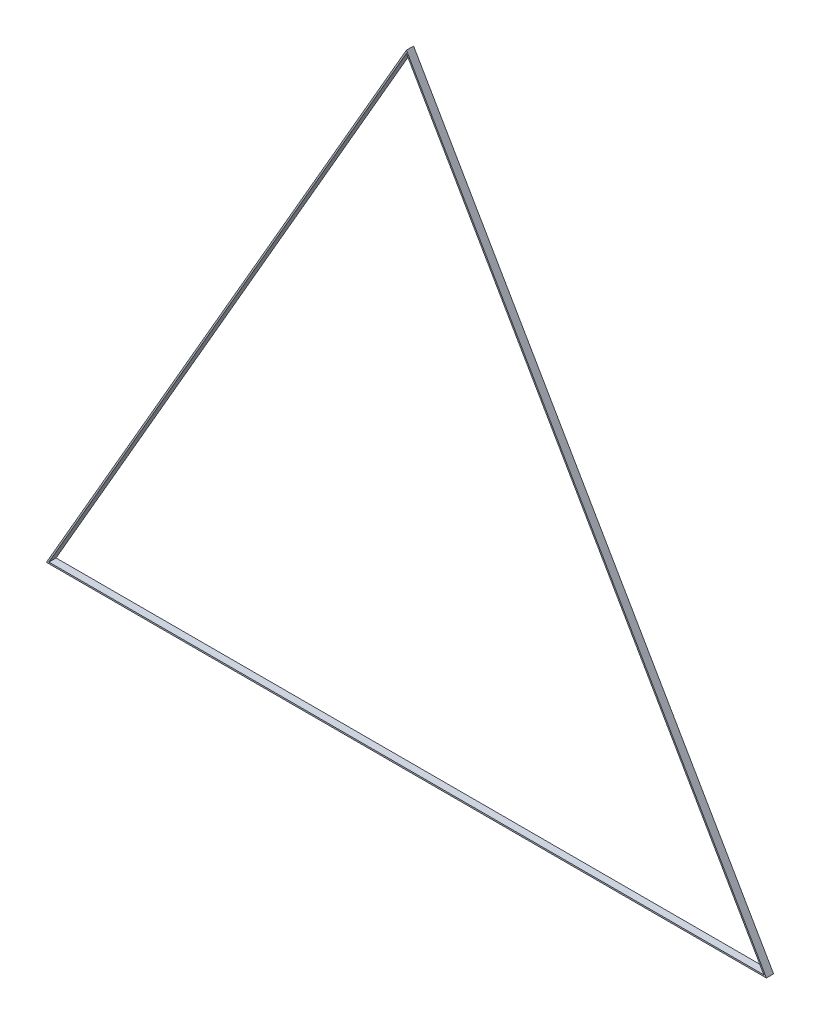
from build123d import *

# Parameters (mm, degrees)
BOSS_EXTRU_1_DEPTH      = 10
ENL_V_MAT_EXTRU_1_DEPTH = 10


with BuildPart() as part:
    # Esquisse1 → Boss.-Extru.1 (new body)
    with BuildSketch(Plane.XY):
        Polygon((-500, 0), (0, 866.025403784), (500, 0), align=None)
    extrude(amount=BOSS_EXTRU_1_DEPTH)

    # Esquisse2 → Enlèv. mat.-Extru.1 (cut)
    with BuildSketch(Plane.XY.offset(10)):
        Polygon((-496.535898385, 2), (0, 862.025403784), (496.535898385, 2), align=None)
    extrude(amount=-ENL_V_MAT_EXTRU_1_DEPTH, mode=Mode.SUBTRACT)


solid = part.part
